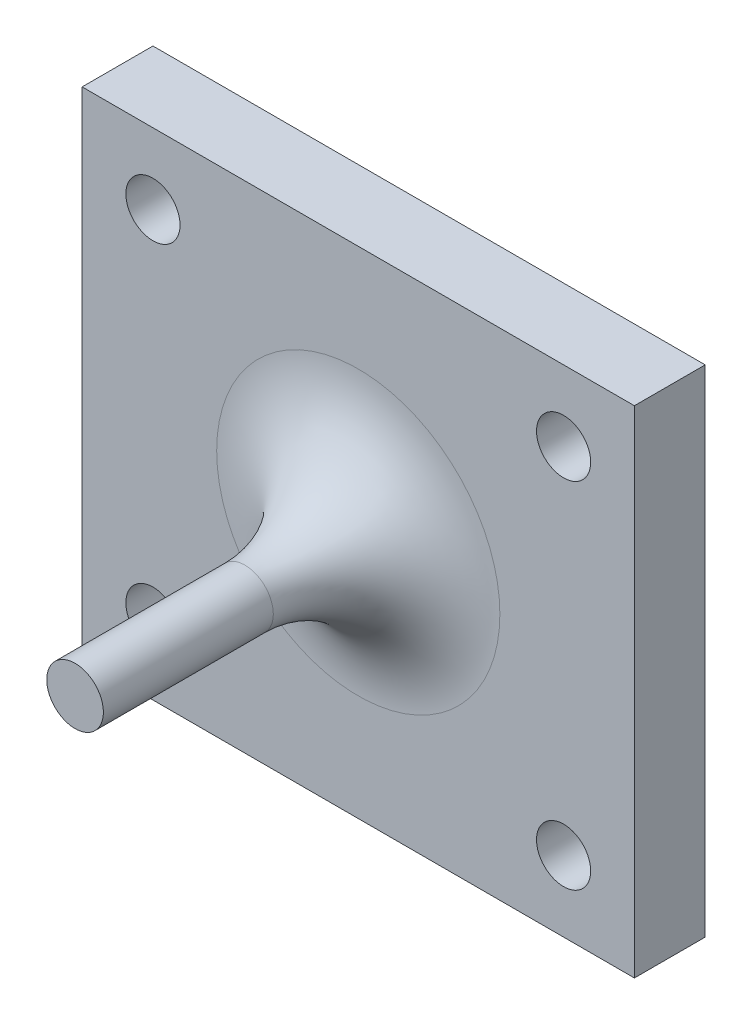
from build123d import *

# Parameters (mm, degrees)
SKETCH1_W           = 39
SKETCH1_H           = 35
SKETCH1_R           = 1.912731322
BOSS_EXTRUDE1_DEPTH = 5
SKETCH2_R           = 2
BOSS_EXTRUDE2_DEPTH = 20
FILLET1_R           = 8


with BuildPart() as part:
    # Sketch1 → Boss-Extrude1 (new body)
    with BuildSketch(Plane.XY):
        Rectangle(SKETCH1_W, SKETCH1_H)
        with Locations((14.5, -12.5)):
            Circle(SKETCH1_R, mode=Mode.SUBTRACT)
        with Locations((14.5, 12.5)):
            Circle(SKETCH1_R, mode=Mode.SUBTRACT)
        with Locations((-14.5, -12.5)):
            Circle(SKETCH1_R, mode=Mode.SUBTRACT)
        with Locations((-14.5, 12.5)):
            Circle(SKETCH1_R, mode=Mode.SUBTRACT)
    extrude(amount=BOSS_EXTRUDE1_DEPTH)

    # Sketch2 → Boss-Extrude2 (add)
    with BuildSketch(Plane.XY.offset(5)):
        Circle(SKETCH2_R)
    extrude(amount=BOSS_EXTRUDE2_DEPTH)

    # Fillet1
    fillet1_edges = [part.edges().sort_by_distance(p)[0] for p in [
        (-2, 0, 5),
    ]]
    fillet(fillet1_edges, radius=FILLET1_R)


solid = part.part
